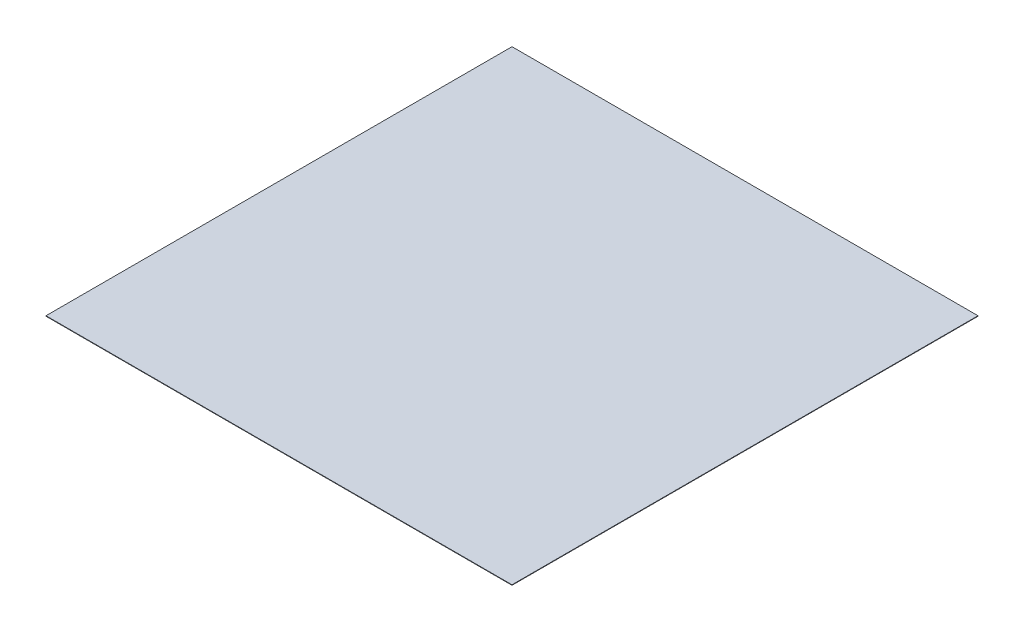
from build123d import *

# Parameters (mm, degrees)
SKETCH1_W           = 1000
SKETCH1_H           = 1
BOSS_EXTRUDE1_DEPTH = 1000


with BuildPart() as part:
    # Sketch1 → Boss-Extrude1 (new body)
    with BuildSketch(Plane.XY):
        with Locations((500, 0.5)):
            Rectangle(SKETCH1_W, SKETCH1_H)
    extrude(amount=BOSS_EXTRUDE1_DEPTH)


solid = part.part
